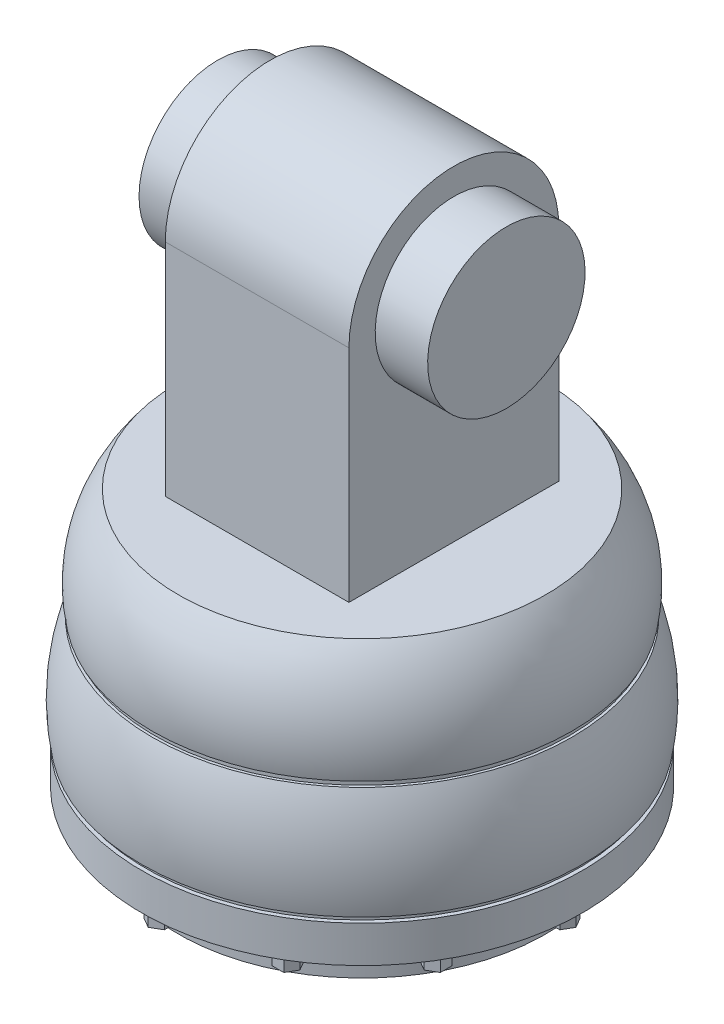
from build123d import *

# Parameters (mm, degrees)
SKETCH2_R           = 39.5
BOSS_EXTRUDE1_DEPTH = 1
SKETCH4_R           = 41.25
BOSS_EXTRUDE2_DEPTH = 1
SKETCH5_R           = 42
BOSS_EXTRUDE3_DEPTH = 7
SKETCH6_R           = 35
BOSS_EXTRUDE4_DEPTH = 7
BOSS_EXTRUDE5_DEPTH = 3
CIRPATTERN1_COUNT   = 12
SKETCH8_R           = 15
BOSS_EXTRUDE6_DEPTH = 10
SKETCH9_W           = 35
SKETCH9_H           = 40
BOSS_EXTRUDE7_DEPTH = 42
BOSS_EXTRUDE8_DEPTH = 35
SKETCH11_R          = 15
BOSS_EXTRUDE9_DEPTH = 10


with BuildPart() as part:
    # Sketch1 → Revolve1 (revolve)
    with BuildSketch(Plane.XY):
        with BuildLine():
            Line((-35, 0), (0, 0))
            Line((0, 0), (0, -20))
            Line((0, -20), (-40, -20))
            ThreePointArc((-40, -20), (-39.657515479, -9.46062113), (-35, 0))
        make_face()
    revolve(axis=Axis((0, 0, 0), (0, -1, 0)))

    # Sketch2 → Boss-Extrude1 (add)
    with BuildSketch(Plane.XZ.offset(20)):
        Circle(SKETCH2_R)
    extrude(amount=BOSS_EXTRUDE1_DEPTH)

    # Sketch3 → Revolve2 (revolve)
    with BuildSketch(Plane(origin=(0, 0, 0), x_dir=(0, 0, -1), z_dir=(1, 0, 0))):
        with BuildLine():
            Line((0, -21), (-40, -21))
            ThreePointArc((-40, -21), (-42.384109041, -30.861589096), (-42, -41))
            Line((-42, -41), (0, -41))
            Line((0, -41), (0, -21))
        make_face()
    revolve(axis=Axis((0, -21, 0), (0, -1, 0)))

    # Sketch4 → Boss-Extrude2 (add)
    with BuildSketch(Plane.XZ.offset(41)):
        Circle(SKETCH4_R)
    extrude(amount=BOSS_EXTRUDE2_DEPTH)

    # Sketch5 → Boss-Extrude3 (add)
    with BuildSketch(Plane.XZ.offset(42)):
        Circle(SKETCH5_R)
    extrude(amount=BOSS_EXTRUDE3_DEPTH)

    # Sketch6 → Boss-Extrude4 (add)
    with BuildSketch(Plane.XZ.offset(49)):
        Circle(SKETCH6_R)
    extrude(amount=BOSS_EXTRUDE4_DEPTH)

    # Sketch7 → Boss-Extrude5 (add)
    with BuildSketch(Plane.XZ.offset(49)):
        Polygon((40.75, 0), (39.625, 1.948557159), (37.375, 1.948557159), (36.25, 0), (37.375, -1.948557159), (39.625, -1.948557159), align=None)
        Polygon((39.047649731, 0.948557159), (37.952350269, 0.948557159), (37.404700538, 0), (37.952350269, -0.948557159), (39.047649731, -0.948557159), (39.595299462, 0), align=None, mode=Mode.SUBTRACT)
    boss_extrude5 = extrude(amount=BOSS_EXTRUDE5_DEPTH)

    # CirPattern1: Boss-Extrude5 ×12 about axis
    cirpattern1_axis = Axis((0, 0, 0), (0, 1, 0))
    for i in range(1, CIRPATTERN1_COUNT):
        add(boss_extrude5.rotate(cirpattern1_axis, i * 360 / CIRPATTERN1_COUNT))

    # Sketch8 → Boss-Extrude6 (add)
    with BuildSketch(Plane.XZ.offset(56)):
        Circle(SKETCH8_R)
    extrude(amount=BOSS_EXTRUDE6_DEPTH)

    # Sketch9 → Boss-Extrude7 (add)
    with BuildSketch(Plane(origin=(0, 0, 0), x_dir=(1, 0, 0), z_dir=(0, 1, 0))):
        Rectangle(SKETCH9_W, SKETCH9_H)
    extrude(amount=BOSS_EXTRUDE7_DEPTH)

    # Sketch10 → Boss-Extrude8 (add)
    with BuildSketch(Plane.ZY.offset(17.5)):
        with BuildLine():
            Line((-20, 42), (20, 42))
            ThreePointArc((20, 42), (0, 62), (-20, 42))
        make_face()
    extrude(amount=-BOSS_EXTRUDE8_DEPTH)

    # Sketch11 → Boss-Extrude9 (add)
    with BuildSketch(Plane.ZY.offset(17.5)):
        with Locations((0, 42)):
            Circle(SKETCH11_R)
    boss_extrude9 = extrude(amount=BOSS_EXTRUDE9_DEPTH)

    # Mirror1: Boss-Extrude9 across plane
    add(boss_extrude9.mirror(Plane(origin=(0, 0, 0), x_dir=(0, 0, 1), z_dir=(1, 0, 0))))


solid = part.part
